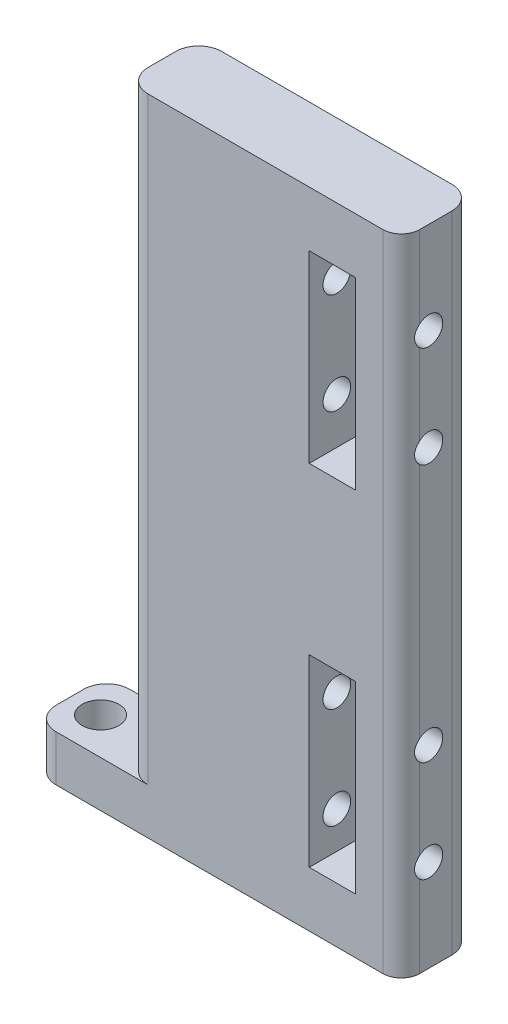
from build123d import *

# Parameters (mm, degrees)
ESBO_O2_W                = 30
ESBO_O2_H                = 70
RESSALTO_EXTRUS_O1_DEPTH = 8
ESBO_O3_R                = 0.75
CORTE_EXTRUS_O1_DEPTH    = 30
FILETE1_R                = 2
ESBO_O17_W               = 10
ESBO_O17_H               = 5
RESSALTO_EXTRUS_O4_DEPTH = 8
ESBO_O20_R               = 2
CORTE_EXTRUS_O9_DEPTH    = 8
FILETE2_R                = 2.5
FILETE3_R                = 2.5
FILETE4_R                = 2.5
FILETE5_R                = 2.5
ESBO_O21_W               = 5
ESBO_O21_H               = 20
CORTE_EXTRUS_O10_DEPTH   = 9
FILETE6_R                = 2.5
ESBO_O22_R               = 1.5
CORTE_EXTRUS_O11_DEPTH   = 20


with BuildPart() as part:
    # Esboço2 → Ressalto-extrusão1 (new body)
    with BuildSketch(Plane.XY):
        with Locations((-52.281248797, -0.107598663)):
            Rectangle(ESBO_O2_W, ESBO_O2_H)
    extrude(amount=RESSALTO_EXTRUS_O1_DEPTH)

    # Esboço3 → Corte-extrusão1 (cut)
    with BuildSketch(Plane(origin=(0, -35.107598663, 0), x_dir=(-1, 0, 0), z_dir=(0, -1, 0))):
        with Locations((58.281248797, -4)):
            Circle(ESBO_O3_R)
        with Locations((63.281248797, -4)):
            Circle(ESBO_O3_R)
    extrude(amount=-CORTE_EXTRUS_O1_DEPTH, mode=Mode.SUBTRACT)

    # Filete1
    filete1_edges = [part.edges().sort_by_distance(p)[0] for p in [
        (-37.281248797, -0.107598663, 8),
    ]]
    fillet(filete1_edges, radius=FILETE1_R)

    # Esboço17 → Ressalto-extrusão4 (add)
    with BuildSketch(Plane(origin=(0, 0, 0), x_dir=(-1, 0, 0), z_dir=(0, 0, -1))):
        with Locations((72.281248797, -32.607598663)):
            Rectangle(ESBO_O17_W, ESBO_O17_H)
    extrude(amount=-RESSALTO_EXTRUS_O4_DEPTH)

    # Esboço20 → Corte-extrusão9 (cut)
    with BuildSketch(Plane.XZ.offset(35.107598663)):
        with Locations((-73.951248797, 4)):
            Circle(ESBO_O20_R)
    extrude(amount=-CORTE_EXTRUS_O9_DEPTH, mode=Mode.SUBTRACT)

    # Filete2
    filete2_edges = [part.edges().sort_by_distance(p)[0] for p in [
        (-67.281248797, 2.392401337, 8),
    ]]
    fillet(filete2_edges, radius=FILETE2_R)

    # Filete3
    filete3_edges = [part.edges().sort_by_distance(p)[0] for p in [
        (-67.281248797, 2.392401337, 0),
    ]]
    fillet(filete3_edges, radius=FILETE3_R)

    # Filete4
    filete4_edges = [part.edges().sort_by_distance(p)[0] for p in [
        (-77.281248797, -32.607598663, 8),
    ]]
    fillet(filete4_edges, radius=FILETE4_R)

    # Filete5
    filete5_edges = [part.edges().sort_by_distance(p)[0] for p in [
        (-77.281248797, -32.607598663, 0),
    ]]
    fillet(filete5_edges, radius=FILETE5_R)

    # Esboço21 → Corte-extrusão10 (cut, through all)
    with BuildSketch(Plane.XY.offset(8)):
        with Locations((-44.781248797, 18.892401337)):
            Rectangle(ESBO_O21_W, ESBO_O21_H)
        with Locations((-44.781248797, -19.107598663)):
            Rectangle(ESBO_O21_W, ESBO_O21_H)
    extrude(amount=-CORTE_EXTRUS_O10_DEPTH, mode=Mode.SUBTRACT)

    # Filete6
    filete6_edges = [part.edges().sort_by_distance(p)[0] for p in [
        (-37.281248797, -0.107598663, 0),
    ]]
    fillet(filete6_edges, radius=FILETE6_R)

    # Esboço22 → Corte-extrusão11 (cut)
    with BuildSketch(Plane(origin=(-37.281248797, 0, 0), x_dir=(0, 0, -1), z_dir=(1, 0, 0))):
        with Locations((-5, -25.107598663)):
            Circle(ESBO_O22_R)
        with Locations((-5, -14.107598663)):
            Circle(ESBO_O22_R)
        with Locations((-5, 24.892401337)):
            Circle(ESBO_O22_R)
        with Locations((-5, 13.892401337)):
            Circle(ESBO_O22_R)
    extrude(amount=-CORTE_EXTRUS_O11_DEPTH, mode=Mode.SUBTRACT)


solid = part.part
